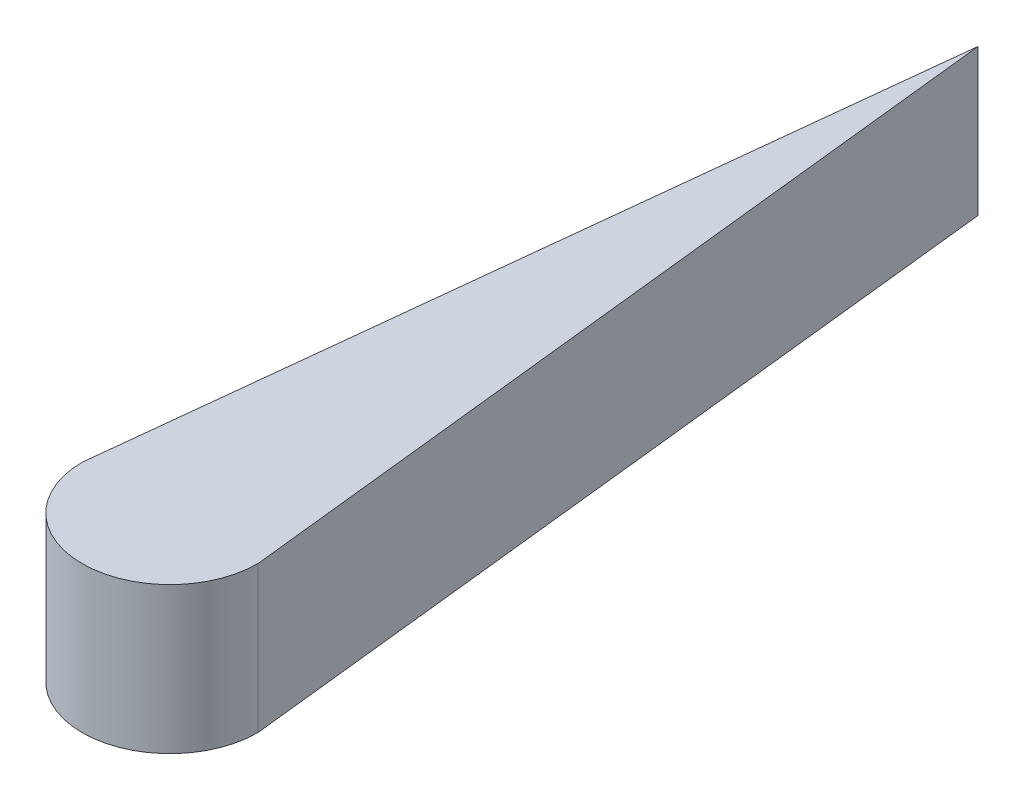
from build123d import *

# Parameters (mm, degrees)
BOSS_EXTRUDE1_DEPTH = 6.35


with BuildPart() as part:
    # Sketch1 → Boss-Extrude1 (new body)
    with BuildSketch(Plane(origin=(0, 0, 0), x_dir=(1, 0, 0), z_dir=(0, 1, 0))):
        with BuildLine():
            ThreePointArc((-3.81, 3.81), (-2.694076836, 1.115923164), (0, 0))
            Line((0, 0), (0, 7.62))
            ThreePointArc((0, 7.62), (-2.387181834, 6.779421306), (-3.721022887, 4.628589444))
            Line((-3.721022887, 4.628589444), (-3.81, 3.81))
        make_face()
        with BuildLine():
            ThreePointArc((-3.721022887, 4.628589444), (-2.387181834, 6.779421306), (0, 7.62))
            Line((0, 7.62), (0, 38.862))
            Line((0, 38.862), (-3.721022887, 4.628589444))
        make_face()
        with BuildLine():
            Line((0, 7.62), (0, 0))
            ThreePointArc((0, 0), (2.694076836, 1.115923164), (3.81, 3.81))
            Line((3.81, 3.81), (3.721022887, 4.628589444))
            ThreePointArc((3.721022887, 4.628589444), (2.387181834, 6.779421306), (0, 7.62))
        make_face()
        with BuildLine():
            Line((0, 38.862), (0, 7.62))
            ThreePointArc((0, 7.62), (2.387181834, 6.779421306), (3.721022887, 4.628589444))
            Line((3.721022887, 4.628589444), (0, 38.862))
        make_face()
    extrude(amount=BOSS_EXTRUDE1_DEPTH)


solid = part.part
